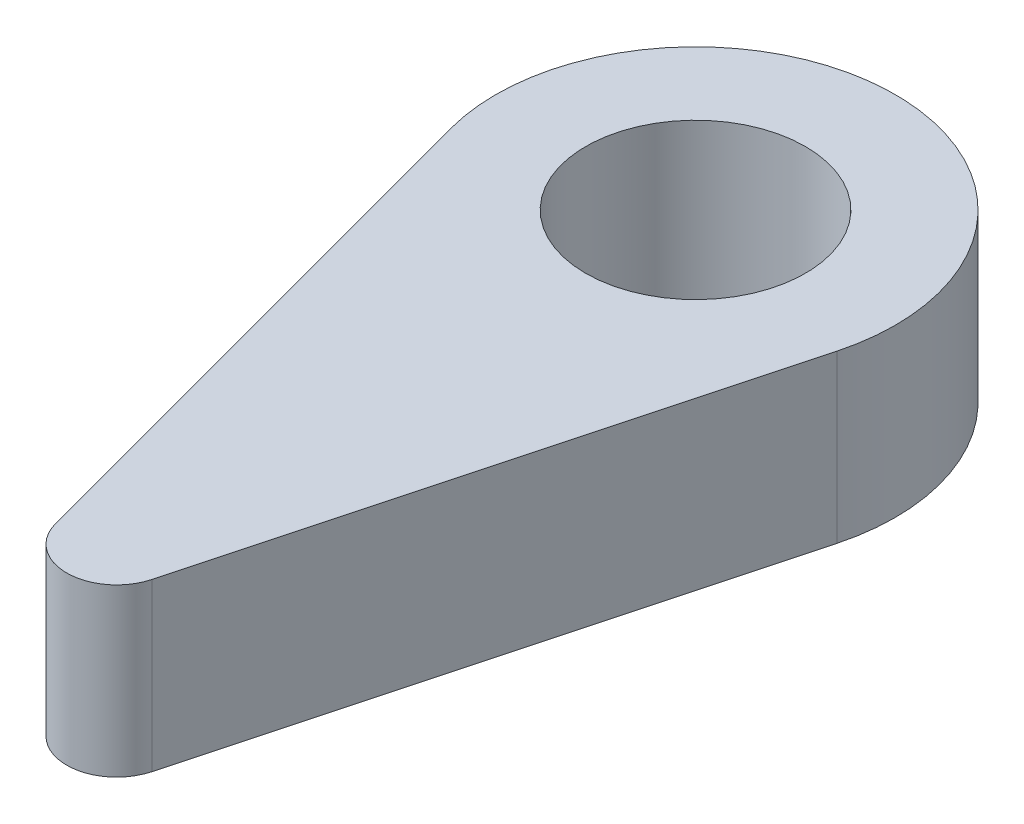
from build123d import *

# Parameters (mm, degrees)
SKETCH_1_R      = 6
SKETCH_1_R_2    = 3.3
EXTRUDE_1_DEPTH = 5


with BuildPart() as part:
    # 스케치1 → 보스-돌출1 (new body)
    with BuildSketch(Plane(origin=(0, 0, 0), x_dir=(1, 0, 0), z_dir=(0, 1, 0))):
        Circle(SKETCH_1_R)
        Circle(SKETCH_1_R_2, mode=Mode.SUBTRACT)
        with BuildLine():
            Line((-5.795554958, -1.552914271), (-1.448888739, -17.774893441))
            ThreePointArc((-1.448888739, -17.774893441), (0, -18.886664873), (1.448888739, -17.774893441))
            Line((1.448888739, -17.774893441), (5.795554958, -1.552914271))
            ThreePointArc((5.795554958, -1.552914271), (0, -6), (-5.795554958, -1.552914271))
        make_face()
    extrude(amount=EXTRUDE_1_DEPTH)


solid = part.part
